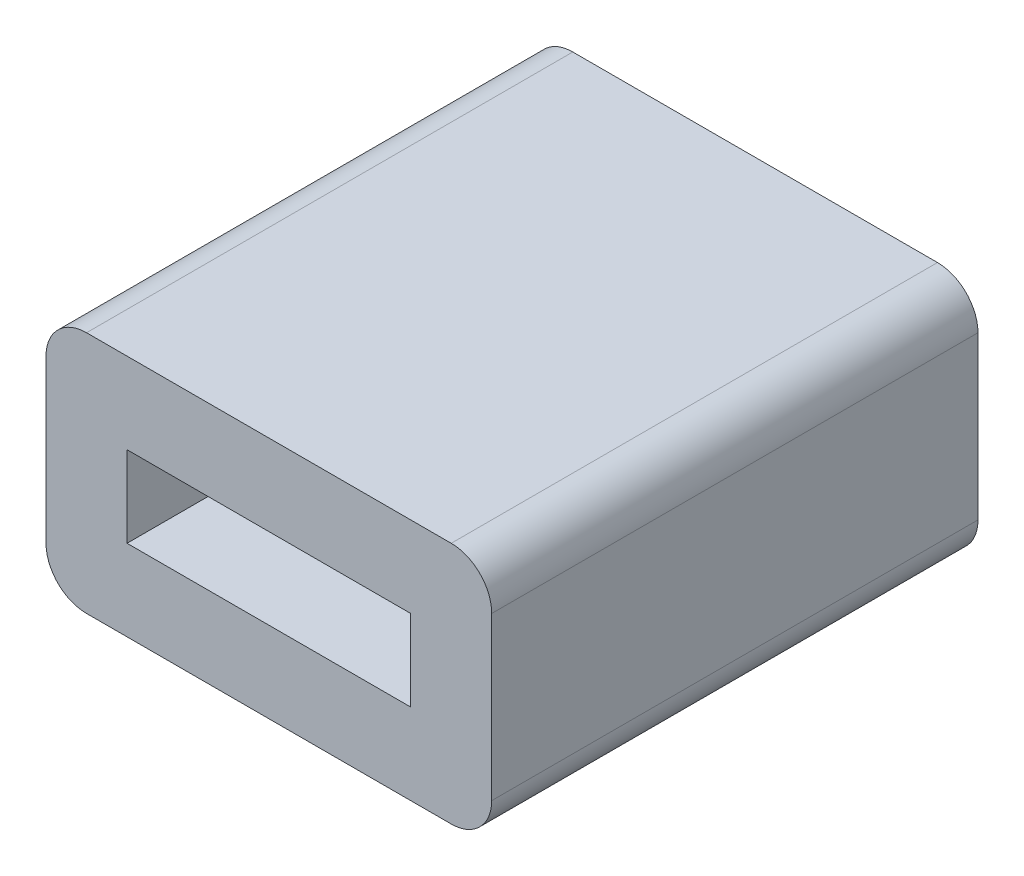
from build123d import *

# Parameters (mm, degrees)
SKETCH_1_W      = 7
SKETCH_1_H      = 2
EXTRUDE_1_DEPTH = 12


with BuildPart() as part:
    # 草图1 → 凸台-拉伸1 (new body)
    with BuildSketch(Plane.XY):
        with BuildLine():
            Line((-4.5, -3), (4.5, -3))
            ThreePointArc((4.5, -3), (5.207106781, -2.707106781), (5.5, -2))
            Line((5.5, -2), (5.5, 2))
            ThreePointArc((5.5, 2), (5.207106781, 2.707106781), (4.5, 3))
            Line((4.5, 3), (-4.5, 3))
            ThreePointArc((-4.5, 3), (-5.207106781, 2.707106781), (-5.5, 2))
            Line((-5.5, 2), (-5.5, -2))
            ThreePointArc((-5.5, -2), (-5.207106781, -2.707106781), (-4.5, -3))
        make_face()
        Rectangle(SKETCH_1_W, SKETCH_1_H, mode=Mode.SUBTRACT)
    extrude(amount=EXTRUDE_1_DEPTH)


solid = part.part
